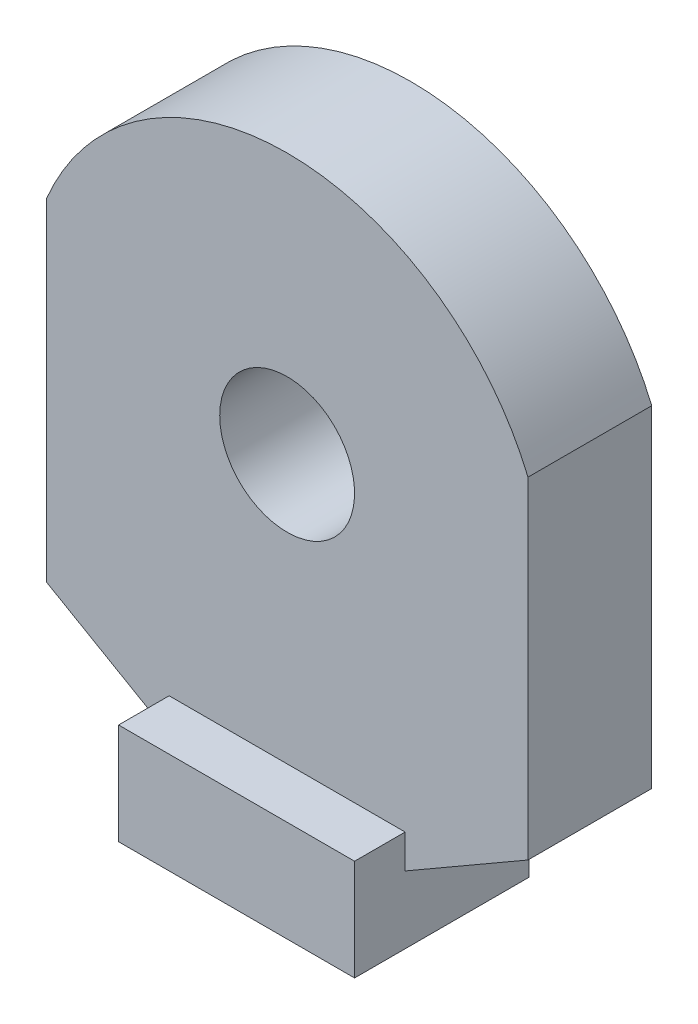
from build123d import *

# Parameters (mm, degrees)
ESQUISSE1_R        = 4
BOSS_EXTRU_1_DEPTH = 7.34
ESQUISSE2_W        = 14
ESQUISSE2_H        = 6
BOSS_EXTRU_2_DEPTH = 3


with BuildPart() as part:
    # Esquisse1 → Boss.-Extru.1 (new body)
    with BuildSketch(Plane.XY):
        with BuildLine():
            Line((-14.29, -13.691116538), (-14.29, 5.977959518))
            ThreePointArc((-14.29, 5.977959518), (0, 15.49), (14.29, 5.977959518))
            Line((14.29, 5.977959518), (14.29, -13.691116538))
            Line((14.29, -13.691116538), (7, -17.9))
            Line((7, -17.9), (7, -21.9))
            Line((7, -21.9), (-7, -21.9))
            Line((-7, -21.9), (-7, -17.9))
            Line((-7, -17.9), (-14.29, -13.691116538))
        make_face()
        Circle(ESQUISSE1_R, mode=Mode.SUBTRACT)
    extrude(amount=BOSS_EXTRU_1_DEPTH)

    # Esquisse2 → Boss.-Extru.2 (add)
    with BuildSketch(Plane.XY.offset(7.34)):
        with Locations((0, -18.9)):
            Rectangle(ESQUISSE2_W, ESQUISSE2_H)
    extrude(amount=BOSS_EXTRU_2_DEPTH)


solid = part.part
